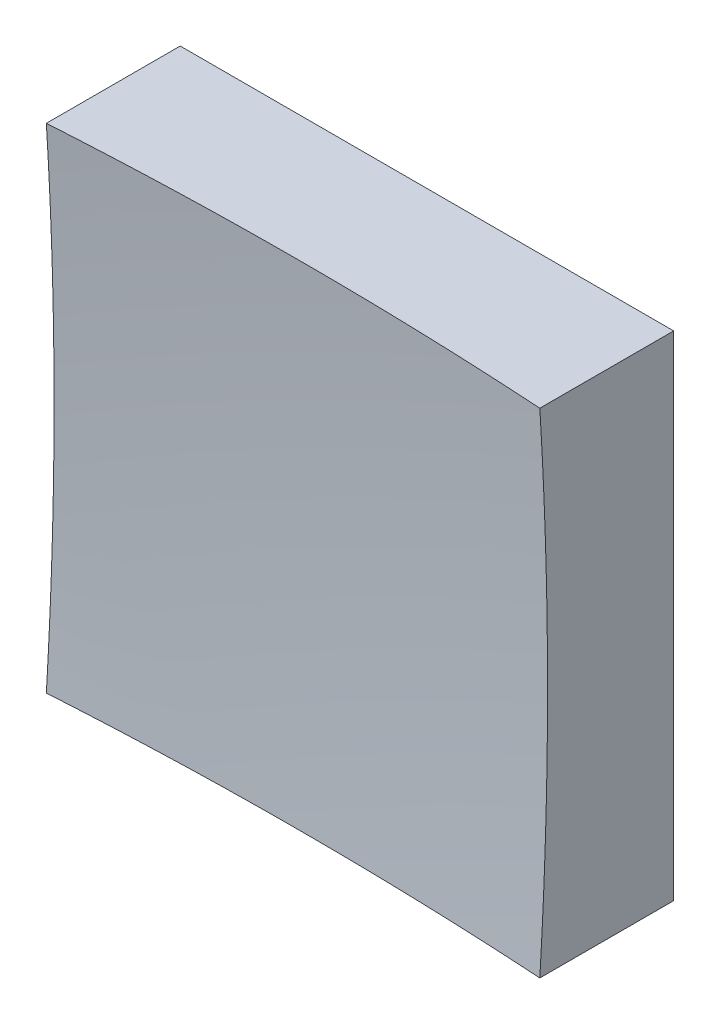
from build123d import *

# Parameters (mm, degrees)
SKETCH_1_W      = 12.5
SKETCH_1_H      = 12.5
EXTRUDE_1_DEPTH = 10


with BuildPart() as part:
    # 草图1 → 凸台-拉伸1 (new body)
    with BuildSketch(Plane.XY):
        Rectangle(SKETCH_1_W, SKETCH_1_H)
    extrude(amount=EXTRUDE_1_DEPTH)

    # 草图2 → 切除-旋转2 (revolve, cut)
    with BuildSketch(Plane(origin=(0, 0, 0), x_dir=(1, 0, 0), z_dir=(0, 1, 0))):
        with BuildLine():
            Line((97.484546181, -80.711813537), (0, -80.711813537))
            Line((0, -80.711813537), (0, -3))
            ThreePointArc((0, -3), (62.334506309, -24.805311413), (97.484546181, -80.711813537))
        make_face()
    revolve(axis=Axis((0, 0, 80.711813537), (0, 0, -1)), mode=Mode.SUBTRACT)


solid = part.part
